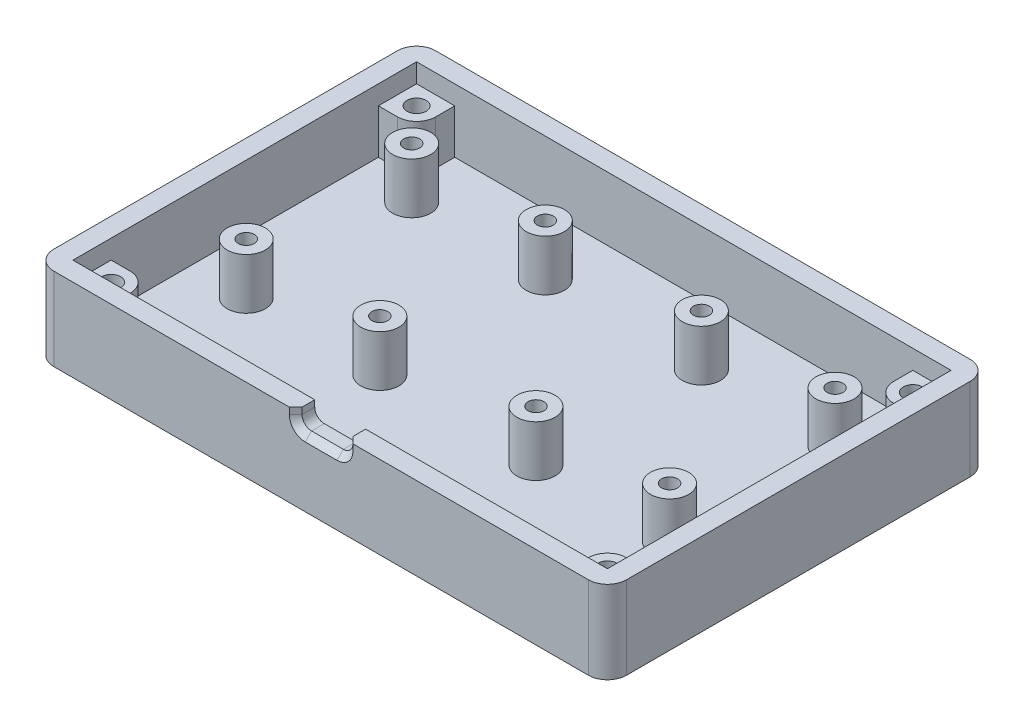
from build123d import *

# Parameters (mm, degrees)
SKETCH_2_W               = 90
SKETCH_2_H               = 60
EXTRUDE_1_DEPTH          = 3
SKETCH_4_R               = 3
SKETCH_4_R_2             = 1.25
EXTRUDE_2_DEPTH          = 8
SKETCH_5_W               = 90
SKETCH_5_H               = 60
SKETCH_5_W_2             = 84
SKETCH_5_H_2             = 54
EXTRUDE_3_DEPTH          = 10
SKETCH_7_R               = 1.5
EXTRUDE_4_DEPTH          = 7
SKETCH_8_R               = 1.5
CUT_EXTRUDE_1_DEPTH      = 7
CUT_EXTRUDE_1_DEPTH_BACK = 7
CHAMFER_1_SIZE           = 2.5
FILLET_1_R               = 3
CUT_EXTRUDE_2_DEPTH      = 9
CHAMFER_2_SIZE           = 1


with BuildPart() as part:
    # Эскиз2 → Бобышка-Вытянуть1 (new body)
    with BuildSketch(Plane(origin=(0, 0, 0), x_dir=(1, 0, 0), z_dir=(0, 1, 0))):
        with Locations((-3.203448276, -4.55862069)):
            Rectangle(SKETCH_2_W, SKETCH_2_H)
    extrude(amount=EXTRUDE_1_DEPTH)

    # Эскиз4 → Бобышка-Вытянуть2 (add)
    with BuildSketch(Plane(origin=(0, 3, 0), x_dir=(1, 0, 0), z_dir=(0, 1, 0))):
        with Locations((-36.468484305, 12.94137931)):
            Circle(SKETCH_4_R)
        with Locations((-36.468484305, 12.94137931)):
            Circle(SKETCH_4_R_2, mode=Mode.SUBTRACT)
        with Locations((-15.468484305, 12.94137931)):
            Circle(SKETCH_4_R)
        with Locations((-15.468484305, 12.94137931)):
            Circle(SKETCH_4_R_2, mode=Mode.SUBTRACT)
        with Locations((-15.468484305, -13.05862069)):
            Circle(SKETCH_4_R)
        with Locations((-15.468484305, -13.05862069)):
            Circle(SKETCH_4_R_2, mode=Mode.SUBTRACT)
        with Locations((-36.468484305, -13.05862069)):
            Circle(SKETCH_4_R)
        with Locations((-36.468484305, -13.05862069)):
            Circle(SKETCH_4_R_2, mode=Mode.SUBTRACT)
        with Locations((9.061587753, -13.05862069)):
            Circle(SKETCH_4_R)
        with Locations((9.061587753, -13.05862069)):
            Circle(SKETCH_4_R_2, mode=Mode.SUBTRACT)
        with Locations((30.061587753, -13.05862069)):
            Circle(SKETCH_4_R)
        with Locations((30.061587753, -13.05862069)):
            Circle(SKETCH_4_R_2, mode=Mode.SUBTRACT)
        with Locations((9.061587753, 12.94137931)):
            Circle(SKETCH_4_R)
        with Locations((9.061587753, 12.94137931)):
            Circle(SKETCH_4_R_2, mode=Mode.SUBTRACT)
        with Locations((30.061587753, 12.94137931)):
            Circle(SKETCH_4_R)
        with Locations((30.061587753, 12.94137931)):
            Circle(SKETCH_4_R_2, mode=Mode.SUBTRACT)
    extrude(amount=EXTRUDE_2_DEPTH)

    # Эскиз5 → Бобышка-Вытянуть3 (add)
    with BuildSketch(Plane(origin=(0, 3, 0), x_dir=(1, 0, 0), z_dir=(0, 1, 0))):
        with Locations((-3.203448276, -4.55862069)):
            Rectangle(SKETCH_5_W, SKETCH_5_H)
        with Locations((-3.203448276, -4.55862069)):
            Rectangle(SKETCH_5_W_2, SKETCH_5_H_2, mode=Mode.SUBTRACT)
    extrude(amount=EXTRUDE_3_DEPTH)

    # Эскиз7 → Бобышка-Вытянуть4 (add)
    with BuildSketch(Plane(origin=(0, 3, 0), x_dir=(1, 0, 0), z_dir=(0, 1, 0))):
        with BuildLine():
            Line((-39.203448276, 19.44137931), (-39.203448276, 22.44137931))
            Line((-39.203448276, 22.44137931), (-45.203448276, 22.44137931))
            Line((-45.203448276, 22.44137931), (-45.203448276, 16.44137931))
            Line((-45.203448276, 16.44137931), (-42.203448276, 16.44137931))
            ThreePointArc((-42.203448276, 16.44137931), (-40.082127932, 17.320058967), (-39.203448276, 19.44137931))
        make_face()
        with Locations((-42.203448276, 19.44137931)):
            Circle(SKETCH_7_R, mode=Mode.SUBTRACT)
        with BuildLine():
            Line((38.796551724, 22.44137931), (32.796551724, 22.44137931))
            Line((32.796551724, 22.44137931), (32.796551724, 19.44137931))
            ThreePointArc((32.796551724, 19.44137931), (33.675231381, 17.320058967), (35.796551724, 16.44137931))
            Line((35.796551724, 16.44137931), (38.796551724, 16.44137931))
            Line((38.796551724, 16.44137931), (38.796551724, 22.44137931))
        make_face()
        with Locations((35.796551724, 19.44137931)):
            Circle(SKETCH_7_R, mode=Mode.SUBTRACT)
        with BuildLine():
            Line((32.796551724, -28.55862069), (32.796551724, -31.55862069))
            Line((32.796551724, -31.55862069), (38.796551724, -31.55862069))
            Line((38.796551724, -31.55862069), (38.796551724, -25.55862069))
            Line((38.796551724, -25.55862069), (35.796551724, -25.55862069))
            ThreePointArc((35.796551724, -25.55862069), (33.675231381, -26.437300346), (32.796551724, -28.55862069))
        make_face()
        with Locations((35.796551724, -28.55862069)):
            Circle(SKETCH_7_R, mode=Mode.SUBTRACT)
        with BuildLine():
            Line((-45.203448276, -31.55862069), (-39.203448276, -31.55862069))
            Line((-39.203448276, -31.55862069), (-39.203448276, -28.55862069))
            ThreePointArc((-39.203448276, -28.55862069), (-40.082127932, -26.437300346), (-42.203448276, -25.55862069))
            Line((-42.203448276, -25.55862069), (-45.203448276, -25.55862069))
            Line((-45.203448276, -25.55862069), (-45.203448276, -31.55862069))
        make_face()
        with Locations((-42.203448276, -28.55862069)):
            Circle(SKETCH_7_R, mode=Mode.SUBTRACT)
    extrude(amount=EXTRUDE_4_DEPTH)

    # Эскиз8 → Вырез-Вытянуть1 (cut, two sides)
    with BuildSketch(Plane(origin=(0, 3, 0), x_dir=(1, 0, 0), z_dir=(0, 1, 0))) as cut_extrude_1_sk:
        with Locations((-42.203448276, 19.44137931)):
            Circle(SKETCH_8_R)
        with Locations((35.796551724, 19.44137931)):
            Circle(SKETCH_8_R)
        with Locations((35.796551724, -28.55862069)):
            Circle(SKETCH_8_R)
        with Locations((-42.203448276, -28.55862069)):
            Circle(SKETCH_8_R)
    extrude(amount=CUT_EXTRUDE_1_DEPTH, mode=Mode.SUBTRACT)
    extrude(cut_extrude_1_sk.sketch, amount=-CUT_EXTRUDE_1_DEPTH_BACK, mode=Mode.SUBTRACT)

    # Фаска1
    chamfer_1_edges = [part.edges().sort_by_distance(p)[0] for p in [
        (34.296551724, 0, 28.55862069),
        (-43.703448276, 0, -19.44137931),
        (-43.703448276, 0, 28.55862069),
        (34.296551724, 0, -19.44137931),
    ]]
    chamfer(chamfer_1_edges, length=CHAMFER_1_SIZE)

    # Скругление1
    fillet_1_edges = [part.edges().sort_by_distance(p)[0] for p in [
        (-48.203448276, 6.5, -25.44137931),
        (41.796551724, 6.5, -25.44137931),
        (41.796551724, 6.5, 34.55862069),
        (-48.203448276, 6.5, 34.55862069),
    ]]
    fillet(fillet_1_edges, radius=FILLET_1_R)

    # Эскиз9 → Вырез-Вытянуть2 (cut)
    with BuildSketch(Plane.XY.offset(34.55862069)):
        with BuildLine():
            Line((-5.703448276, 15.5), (-0.703448276, 15.5))
            ThreePointArc((-0.703448276, 15.5), (0.357211896, 15.060660172), (0.796551724, 14))
            Line((0.796551724, 14), (0.796551724, 12))
            ThreePointArc((0.796551724, 12), (0.357211896, 10.939339828), (-0.703448276, 10.5))
            Line((-0.703448276, 10.5), (-5.703448276, 10.5))
            ThreePointArc((-5.703448276, 10.5), (-6.764108448, 10.939339828), (-7.203448276, 12))
            Line((-7.203448276, 12), (-7.203448276, 14))
            ThreePointArc((-7.203448276, 14), (-6.764108448, 15.060660172), (-5.703448276, 15.5))
        make_face()
    extrude(amount=-CUT_EXTRUDE_2_DEPTH, mode=Mode.SUBTRACT)

    # Фаска2
    chamfer_2_edges = [part.edges().sort_by_distance(p)[0] for p in [
        (-7.203448276, 12.5, 34.55862069),
        (-6.764108448, 10.939339828, 34.55862069),
        (-3.203448276, 10.5, 34.55862069),
        (0.357211896, 10.939339828, 34.55862069),
        (0.796551724, 12.5, 34.55862069),
    ]]
    chamfer(chamfer_2_edges, length=CHAMFER_2_SIZE)


solid = part.part
